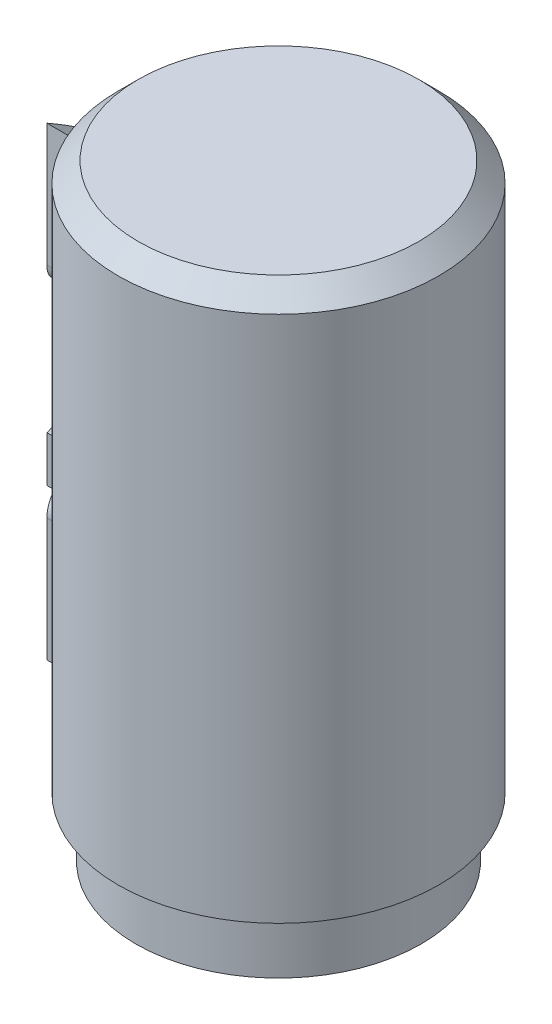
from build123d import *

# Parameters (mm, degrees)
CHAMFER1_SIZE                        = 2.54
SKETCH6_R                            = 18.2245
SKETCH6_R_2                          = 16.9545
BOSS_EXTRUDE2_DEPTH                  = 3.81
CUT_EXTRUDE3_REACH                   = 85.483
CUT_EXTRUDE3_END_RADIUS              = 16.9545
BOSS_EXTRUDE3_REACH                  = 85.483
BOSS_EXTRUDE3_END_RADIUS             = 16.9545
BOSS_EXTRUDE3_DIRECTION_2_REACH      = 85.483
BOSS_EXTRUDE3_DIRECTION_2_END_RADIUS = 23.495


with BuildPart() as part:
    # Sketch2 → Revolve1 (revolve)
    with BuildSketch(Plane.XY, mode=Mode.PRIVATE) as revolve1_sk:
        Polygon((20.447, 0), (20.447, 69.85), (0, 69.85), (0, 63.5), (16.9545, 63.5), (16.9545, -3.81), (18.2245, -3.81), (18.2245, 0), align=None)
    revolve(revolve1_sk.sketch.rotate(Axis((0, 86.868, 0), (0, -1, 0)), 90), axis=Axis((0, 86.868, 0), (0, -1, 0)))

    # Chamfer1
    chamfer1_edges = [part.edges().sort_by_distance(p)[0] for p in [
        (0, 69.85, -20.447),
    ]]
    chamfer(chamfer1_edges, length=CHAMFER1_SIZE)

    # Sketch6 → Boss-Extrude2 (add)
    with BuildSketch(Plane.XZ.offset(3.81)):
        with Locations(Location((0, 0, 0), (0, 0, 90))):
            Circle(SKETCH6_R)
        with Locations(Location((0, 0, 0), (0, 0, 90))):
            Circle(SKETCH6_R_2, mode=Mode.SUBTRACT)
    extrude(amount=BOSS_EXTRUDE2_DEPTH)

    # Cut-Extrude3: up to this cylinder (the profile starts outside it)
    cut_extrude3_end = Plane(origin=(0, 36.232285, 0), z_dir=(0, 1, 0)) * Cylinder(CUT_EXTRUDE3_END_RADIUS, 239.573606, mode=Mode.PRIVATE)
    # Sketch4 → Cut-Extrude3 (cut, up to the surface)
    with BuildSketch(Plane.ZY.offset(20.447), mode=Mode.PRIVATE) as cut_extrude3_sk1:
        with BuildLine():
            Line((-9.886227081, 18.750365384), (2.44601977, 18.750365384))
            Line((2.44601977, 18.750365384), (2.44601977, 9.708915489))
            Line((2.44601977, 9.708915489), (7.179752601, 7.05378365))
            Line((7.179752601, 7.05378365), (7.179752601, 22.749864357))
            ThreePointArc((7.179752601, 22.749864357), (6.435803825, 24.545915581), (4.639752601, 25.289864357))
            Line((4.639752601, 25.289864357), (-9.886227081, 25.289864357))
            Line((-9.886227081, 25.289864357), (-9.886227081, 18.750365384))
        make_face()
    cut_extrude3_tool1 = extrude(cut_extrude3_sk1.sketch, amount=-CUT_EXTRUDE3_REACH, mode=Mode.PRIVATE) - cut_extrude3_end
    add(cut_extrude3_tool1.solids().sort_by_distance((-20.447, 19.382982, 0.508555))[0], mode=Mode.SUBTRACT)
    # Sketch4 → Cut-Extrude3 (cut, up to the surface)
    with BuildSketch(Plane.ZY.offset(20.447), mode=Mode.PRIVATE) as cut_extrude3_sk2:
        with BuildLine():
            Line((-9.886227081, 26.33852022), (7.179752601, 26.33852022))
            Line((7.179752601, 26.33852022), (7.179752601, 32.172887438))
            Line((7.179752601, 32.172887438), (0.045167713, 32.172887438))
            Line((0.045167713, 32.172887438), (3.134689898, 34.31741522))
            Line((3.134689898, 34.31741522), (3.134689898, 40.635289955))
            ThreePointArc((3.134689898, 40.635289955), (-3.375768591, 47.145748444), (-9.886227081, 40.635289955))
            Line((-9.886227081, 40.635289955), (-9.886227081, 26.33852022))
        make_face()
        with BuildLine():
            Line((-5.261318807, 32.172887438), (-1.595383534, 32.172887438))
            Line((-1.595383534, 32.172887438), (-1.595383534, 39.511921236))
            ThreePointArc((-1.595383534, 39.511921236), (-3.428351171, 41.344888872), (-5.261318807, 39.511921236))
            Line((-5.261318807, 39.511921236), (-5.261318807, 32.172887438))
        make_face(mode=Mode.SUBTRACT)
    cut_extrude3_tool2 = extrude(cut_extrude3_sk2.sketch, amount=-CUT_EXTRUDE3_REACH, mode=Mode.PRIVATE) - cut_extrude3_end
    add(cut_extrude3_tool2.solids().sort_by_distance((-20.447, 33.486905, -9.61712))[0], mode=Mode.SUBTRACT)
    # Sketch4 → Cut-Extrude3 (cut, up to the surface)
    with BuildSketch(Plane.ZY.offset(20.447), mode=Mode.PRIVATE) as cut_extrude3_sk3:
        with BuildLine():
            Line((-9.886227081, 48.155164982), (4.639752601, 48.155164982))
            ThreePointArc((4.639752601, 48.155164982), (6.435803825, 48.899113758), (7.179752601, 50.695164982))
            Line((7.179752601, 50.695164982), (7.179752601, 66.374943992))
            Line((7.179752601, 66.374943992), (2.44601977, 63.089121475))
            Line((2.44601977, 63.089121475), (2.44601977, 55.871229104))
            ThreePointArc((2.44601977, 55.871229104), (1.702070994, 54.07517788), (-0.09398023, 53.331229104))
            Line((-0.09398023, 53.331229104), (-9.886227081, 53.331229104))
            Line((-9.886227081, 53.331229104), (-9.886227081, 48.155164982))
        make_face()
    cut_extrude3_tool3 = extrude(cut_extrude3_sk3.sketch, amount=-CUT_EXTRUDE3_REACH, mode=Mode.PRIVATE) - cut_extrude3_end
    add(cut_extrude3_tool3.solids().sort_by_distance((-20.447, 53.081588, -4.990104))[0], mode=Mode.SUBTRACT)


with BuildPart() as cut_extrude3_piece_1:
    # of the separate pieces the step leaves, piece 1, a body of its own (cut_extrude3_pieces)
    add(part.part.solids().sort_by_distance((0, 67.31, 20.447))[0])


with BuildPart() as cut_extrude3_piece_2:
    # of the separate pieces the step leaves, piece 2, a body of its own (cut_extrude3_pieces)
    add(part.part.solids().sort_by_distance((-20.384664834, 32.172887438, -1.595383534))[0])


with BuildPart() as body_3:
    # Boss-Extrude3: up to this cylinder (the profile starts outside it)
    boss_extrude3_end = Plane(origin=(0, 36.232285, 0), z_dir=(0, 1, 0)) * Cylinder(BOSS_EXTRUDE3_END_RADIUS, 239.573606, mode=Mode.PRIVATE)
    # Sketch4_5 → Boss-Extrude3 (new, up to the surface)
    with BuildSketch(Plane.ZY.offset(20.447), mode=Mode.PRIVATE) as boss_extrude3_sk1:
        with BuildLine():
            Line((-9.886227081, 18.750365384), (2.44601977, 18.750365384))
            Line((2.44601977, 18.750365384), (2.44601977, 9.708915489))
            Line((2.44601977, 9.708915489), (7.179752601, 7.05378365))
            Line((7.179752601, 7.05378365), (7.179752601, 22.749864357))
            ThreePointArc((7.179752601, 22.749864357), (6.435803825, 24.545915581), (4.639752601, 25.289864357))
            Line((4.639752601, 25.289864357), (-9.886227081, 25.289864357))
            Line((-9.886227081, 25.289864357), (-9.886227081, 18.750365384))
        make_face()
    boss_extrude3_tool1 = extrude(boss_extrude3_sk1.sketch, amount=-BOSS_EXTRUDE3_REACH, mode=Mode.PRIVATE) - boss_extrude3_end
    add(boss_extrude3_tool1.solids().sort_by_distance((-20.447, 19.382982, 0.508555))[0])
    # Sketch4_5 → Boss-Extrude3 (new, up to the surface)
    with BuildSketch(Plane.ZY.offset(20.447), mode=Mode.PRIVATE) as boss_extrude3_sk2:
        with BuildLine():
            Line((-9.886227081, 26.33852022), (7.179752601, 26.33852022))
            Line((7.179752601, 26.33852022), (7.179752601, 32.172887438))
            Line((7.179752601, 32.172887438), (0.045167713, 32.172887438))
            Line((0.045167713, 32.172887438), (3.134689898, 34.31741522))
            Line((3.134689898, 34.31741522), (3.134689898, 40.635289955))
            ThreePointArc((3.134689898, 40.635289955), (-3.375768591, 47.145748444), (-9.886227081, 40.635289955))
            Line((-9.886227081, 40.635289955), (-9.886227081, 26.33852022))
        make_face()
        with BuildLine():
            Line((-5.261318807, 32.172887438), (-1.595383534, 32.172887438))
            Line((-1.595383534, 32.172887438), (-1.595383534, 39.511921236))
            ThreePointArc((-1.595383534, 39.511921236), (-3.428351171, 41.344888872), (-5.261318807, 39.511921236))
            Line((-5.261318807, 39.511921236), (-5.261318807, 32.172887438))
        make_face(mode=Mode.SUBTRACT)
    boss_extrude3_tool2 = extrude(boss_extrude3_sk2.sketch, amount=-BOSS_EXTRUDE3_REACH, mode=Mode.PRIVATE) - boss_extrude3_end
    add(boss_extrude3_tool2.solids().sort_by_distance((-20.447, 33.486905, -9.61712))[0])
    # Sketch4_5 → Boss-Extrude3 (new, up to the surface)
    with BuildSketch(Plane.ZY.offset(20.447), mode=Mode.PRIVATE) as boss_extrude3_sk3:
        with BuildLine():
            Line((-9.886227081, 48.155164982), (4.639752601, 48.155164982))
            ThreePointArc((4.639752601, 48.155164982), (6.435803825, 48.899113758), (7.179752601, 50.695164982))
            Line((7.179752601, 50.695164982), (7.179752601, 66.374943992))
            Line((7.179752601, 66.374943992), (2.44601977, 63.089121475))
            Line((2.44601977, 63.089121475), (2.44601977, 55.871229104))
            ThreePointArc((2.44601977, 55.871229104), (1.702070994, 54.07517788), (-0.09398023, 53.331229104))
            Line((-0.09398023, 53.331229104), (-9.886227081, 53.331229104))
            Line((-9.886227081, 53.331229104), (-9.886227081, 48.155164982))
        make_face()
    boss_extrude3_tool3 = extrude(boss_extrude3_sk3.sketch, amount=-BOSS_EXTRUDE3_REACH, mode=Mode.PRIVATE) - boss_extrude3_end
    add(boss_extrude3_tool3.solids().sort_by_distance((-20.447, 53.081588, -4.990104))[0])

    # Boss-Extrude3 direction 2: up to this cylinder (the profile starts inside it)
    boss_extrude3_direction_2_end = Plane(origin=(0, 36.232285, 0), z_dir=(0, 1, 0)) * Cylinder(BOSS_EXTRUDE3_DIRECTION_2_END_RADIUS, 252.654606, mode=Mode.PRIVATE)
    # Sketch4_5 → Boss-Extrude3 direction 2 (add, up to the surface)
    with BuildSketch(Plane.ZY.offset(20.447), mode=Mode.PRIVATE) as boss_extrude3_direction_2_sk1:
        with BuildLine():
            Line((-9.886227081, 18.750365384), (2.44601977, 18.750365384))
            Line((2.44601977, 18.750365384), (2.44601977, 9.708915489))
            Line((2.44601977, 9.708915489), (7.179752601, 7.05378365))
            Line((7.179752601, 7.05378365), (7.179752601, 22.749864357))
            ThreePointArc((7.179752601, 22.749864357), (6.435803825, 24.545915581), (4.639752601, 25.289864357))
            Line((4.639752601, 25.289864357), (-9.886227081, 25.289864357))
            Line((-9.886227081, 25.289864357), (-9.886227081, 18.750365384))
        make_face()
    boss_extrude3_direction_2_tool1 = extrude(boss_extrude3_direction_2_sk1.sketch, amount=BOSS_EXTRUDE3_DIRECTION_2_REACH, mode=Mode.PRIVATE) & boss_extrude3_direction_2_end
    add(boss_extrude3_direction_2_tool1.solids().sort_by_distance((-20.447, 19.382982, 0.508555))[0])
    # Sketch4_5 → Boss-Extrude3 direction 2 (add, up to the surface)
    with BuildSketch(Plane.ZY.offset(20.447), mode=Mode.PRIVATE) as boss_extrude3_direction_2_sk2:
        with BuildLine():
            Line((-9.886227081, 26.33852022), (7.179752601, 26.33852022))
            Line((7.179752601, 26.33852022), (7.179752601, 32.172887438))
            Line((7.179752601, 32.172887438), (0.045167713, 32.172887438))
            Line((0.045167713, 32.172887438), (3.134689898, 34.31741522))
            Line((3.134689898, 34.31741522), (3.134689898, 40.635289955))
            ThreePointArc((3.134689898, 40.635289955), (-3.375768591, 47.145748444), (-9.886227081, 40.635289955))
            Line((-9.886227081, 40.635289955), (-9.886227081, 26.33852022))
        make_face()
        with BuildLine():
            Line((-5.261318807, 32.172887438), (-1.595383534, 32.172887438))
            Line((-1.595383534, 32.172887438), (-1.595383534, 39.511921236))
            ThreePointArc((-1.595383534, 39.511921236), (-3.428351171, 41.344888872), (-5.261318807, 39.511921236))
            Line((-5.261318807, 39.511921236), (-5.261318807, 32.172887438))
        make_face(mode=Mode.SUBTRACT)
    boss_extrude3_direction_2_tool2 = extrude(boss_extrude3_direction_2_sk2.sketch, amount=BOSS_EXTRUDE3_DIRECTION_2_REACH, mode=Mode.PRIVATE) & boss_extrude3_direction_2_end
    add(boss_extrude3_direction_2_tool2.solids().sort_by_distance((-20.447, 33.486905, -9.61712))[0])
    # Sketch4_5 → Boss-Extrude3 direction 2 (add, up to the surface)
    with BuildSketch(Plane.ZY.offset(20.447), mode=Mode.PRIVATE) as boss_extrude3_direction_2_sk3:
        with BuildLine():
            Line((-9.886227081, 48.155164982), (4.639752601, 48.155164982))
            ThreePointArc((4.639752601, 48.155164982), (6.435803825, 48.899113758), (7.179752601, 50.695164982))
            Line((7.179752601, 50.695164982), (7.179752601, 66.374943992))
            Line((7.179752601, 66.374943992), (2.44601977, 63.089121475))
            Line((2.44601977, 63.089121475), (2.44601977, 55.871229104))
            ThreePointArc((2.44601977, 55.871229104), (1.702070994, 54.07517788), (-0.09398023, 53.331229104))
            Line((-0.09398023, 53.331229104), (-9.886227081, 53.331229104))
            Line((-9.886227081, 53.331229104), (-9.886227081, 48.155164982))
        make_face()
    boss_extrude3_direction_2_tool3 = extrude(boss_extrude3_direction_2_sk3.sketch, amount=BOSS_EXTRUDE3_DIRECTION_2_REACH, mode=Mode.PRIVATE) & boss_extrude3_direction_2_end
    add(boss_extrude3_direction_2_tool3.solids().sort_by_distance((-20.447, 53.081588, -4.990104))[0])


solid = Compound([cut_extrude3_piece_1.part, cut_extrude3_piece_2.part, body_3.part])
